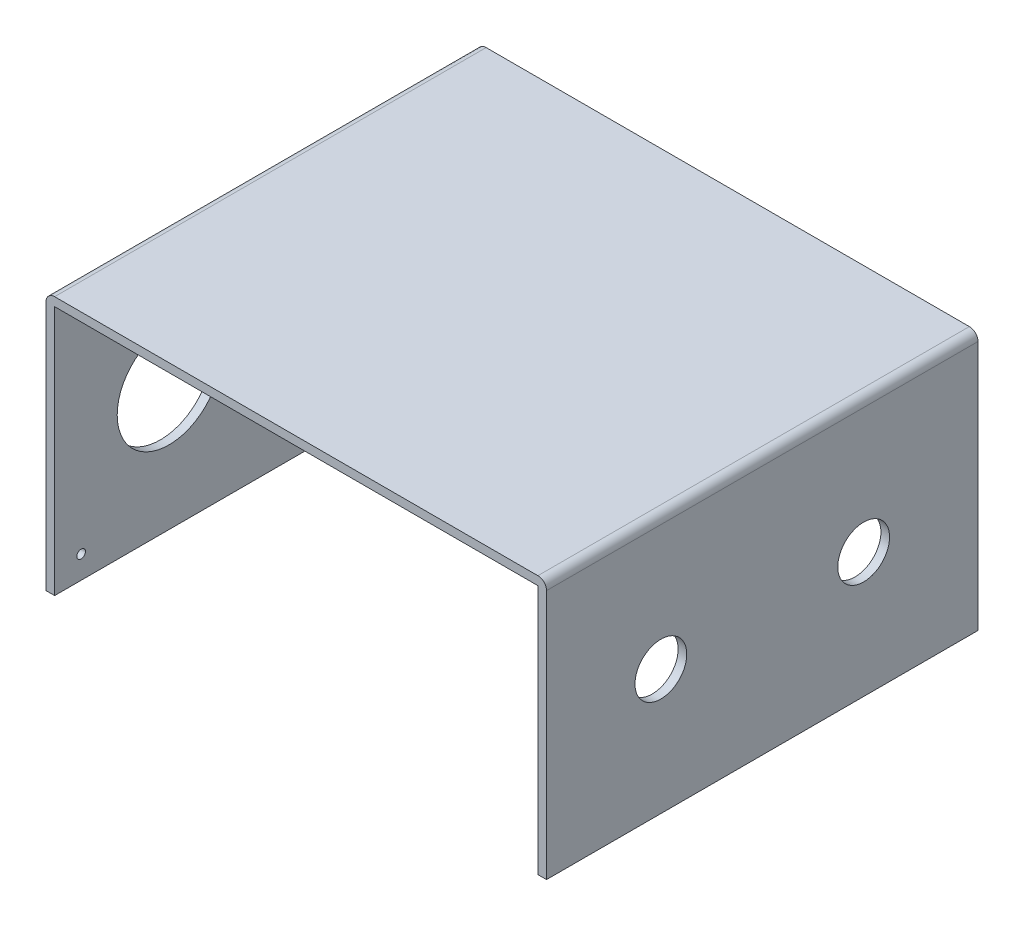
from build123d import *

# Parameters (mm, degrees)
EKSTR_ZYON_NCE1_DEPTH = 50
IZIM2_R               = 3
KES_EKSTR_ZYON1_DEPTH = 78
IZIM3_R               = 0.5
KES_EKSTR_ZYON2_DEPTH = 22
IZIM4_R               = 6
KES_EKSTR_ZYON3_DEPTH = 22


with BuildPart() as part:
    # Çizim1 → Ekstrüzyon-İnce1 (new body)
    with BuildSketch(Plane.XY):
        with BuildLine():
            Line((0, 0), (0, 29))
            ThreePointArc((0, 29), (0.292893219, 29.707106781), (1, 30))
            Line((1, 30), (57, 30))
            ThreePointArc((57, 30), (57.707106781, 29.707106781), (58, 29))
            Line((58, 29), (58, 0))
            Line((58, 0), (57, 0))
            Line((57, 0), (57, 29))
            Line((57, 29), (1, 29))
            Line((1, 29), (1, 0))
            Line((1, 0), (0, 0))
        make_face()
    extrude(amount=EKSTR_ZYON_NCE1_DEPTH)

    # Çizim2 → Kes-Ekstrüzyon1 (cut)
    with BuildSketch(Plane(origin=(58, 0, 0), x_dir=(0, 0, -1), z_dir=(1, 0, 0))):
        with Locations((-36.75, 14.5)):
            Circle(IZIM2_R)
        with Locations((-13.25, 14.5)):
            Circle(IZIM2_R)
    extrude(amount=-KES_EKSTR_ZYON1_DEPTH, mode=Mode.SUBTRACT)

    # Çizim3 → Kes-Ekstrüzyon2 (cut)
    with BuildSketch(Plane.ZY):
        with Locations((46.926319902, 2.636193895)):
            Circle(IZIM3_R)
    extrude(amount=-KES_EKSTR_ZYON2_DEPTH, mode=Mode.SUBTRACT)

    # Çizim4 → Kes-Ekstrüzyon3 (cut)
    with BuildSketch(Plane.ZY):
        with Locations((36.75, 14.5)):
            Circle(IZIM4_R)
    extrude(amount=-KES_EKSTR_ZYON3_DEPTH, mode=Mode.SUBTRACT)


solid = part.part
